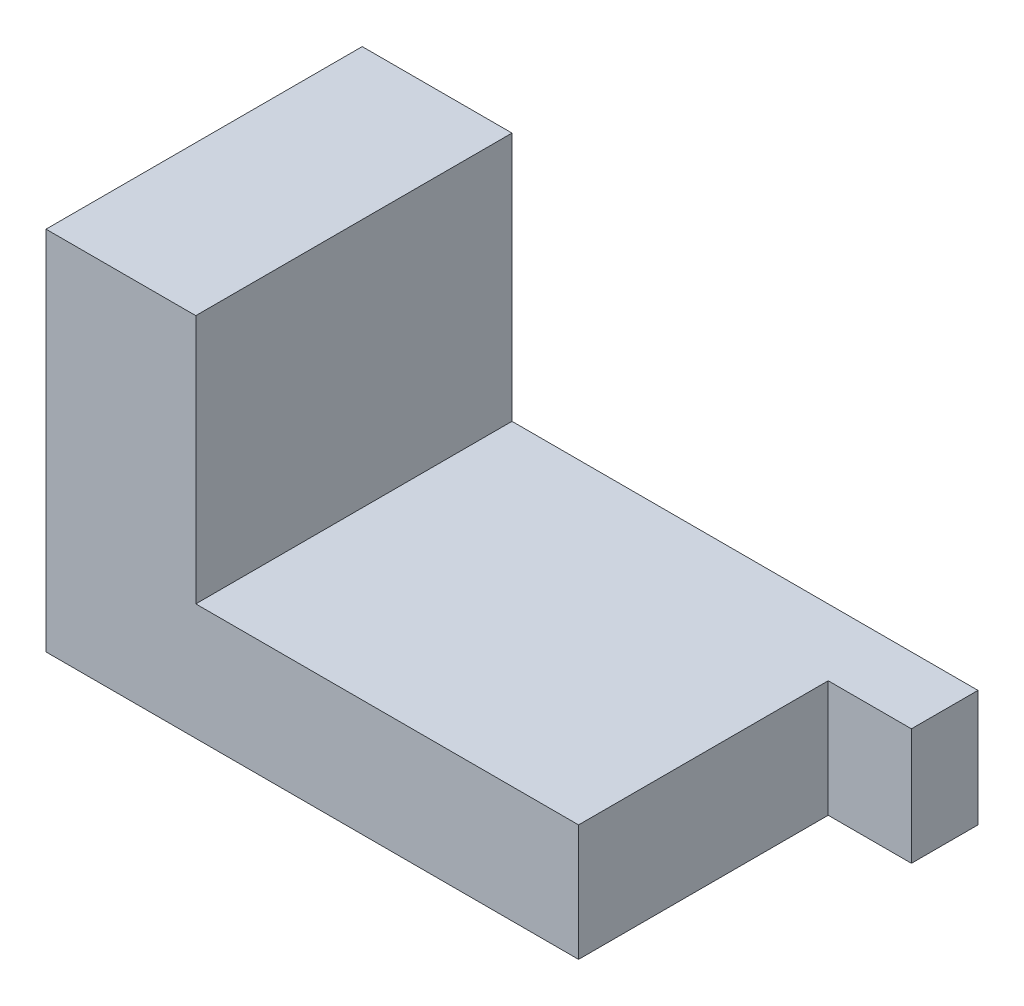
from build123d import *

# Parameters (mm, degrees)
SKETCH1_W           = 32
SKETCH1_H           = 19
BOSS_EXTRUDE1_DEPTH = 7
SKETCH2_W           = 9
SKETCH2_H           = 19
BOSS_EXTRUDE2_DEPTH = 15
SKETCH3_W           = 4
SKETCH3_H           = 7
BOSS_EXTRUDE3_DEPTH = 5


with BuildPart() as part:
    # Sketch1 → Boss-Extrude1 (new body)
    with BuildSketch(Plane(origin=(0, 0, 0), x_dir=(1, 0, 0), z_dir=(0, 1, 0))):
        Rectangle(SKETCH1_W, SKETCH1_H)
    extrude(amount=BOSS_EXTRUDE1_DEPTH)

    # Sketch2 → Boss-Extrude2 (add)
    with BuildSketch(Plane(origin=(0, 7, 0), x_dir=(1, 0, 0), z_dir=(0, 1, 0))):
        with Locations((-11.5, 0)):
            Rectangle(SKETCH2_W, SKETCH2_H)
    extrude(amount=BOSS_EXTRUDE2_DEPTH)

    # Sketch3 → Boss-Extrude3 (add)
    with BuildSketch(Plane(origin=(16, 0, 0), x_dir=(0, 0, -1), z_dir=(1, 0, 0))):
        with Locations((7.5, 3.5)):
            Rectangle(SKETCH3_W, SKETCH3_H)
    extrude(amount=BOSS_EXTRUDE3_DEPTH)


solid = part.part
